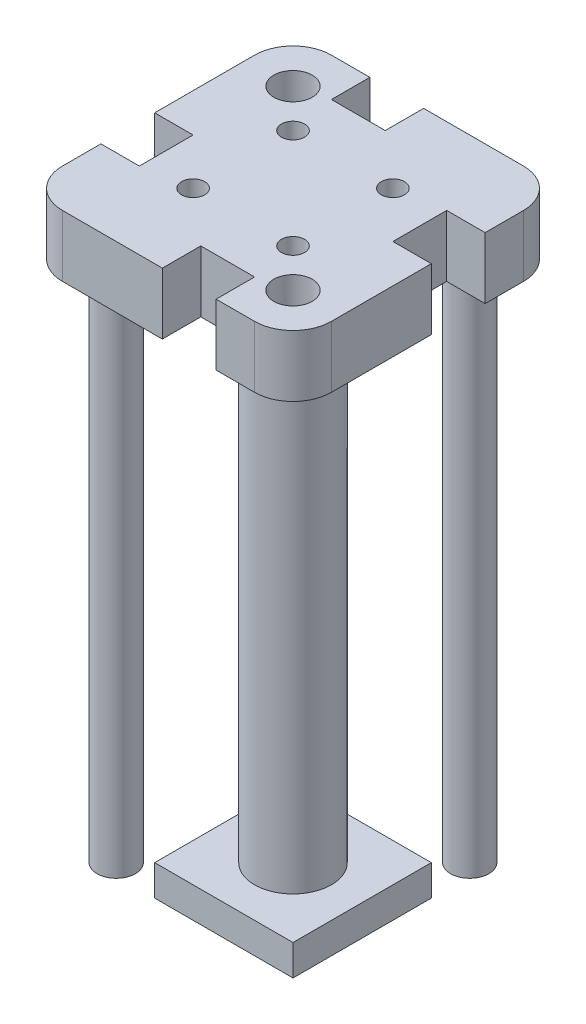
from build123d import *

# Parameters (mm, degrees)
SKETCH1_W           = 35
SKETCH1_H           = 35
BOSS_EXTRUDE1_DEPTH = 8
SKETCH2_W           = 7
SKETCH2_H           = 5
SKETCH2_W_2         = 5
SKETCH2_H_2         = 7
SKETCH2_R           = 1.5
CUT_EXTRUDE1_DEPTH  = 51.139804547
SKETCH2_5_R         = 4
SKETCH2_5_R_2       = 1.5
CUT_EXTRUDE2_DEPTH  = 4
SKETCH2_7_R         = 2.5
SKETCH2_7_R_2       = 5
BOSS_EXTRUDE2_DEPTH = 68
SKETCH3_W           = 18
SKETCH3_H           = 18
BOSS_EXTRUDE3_DEPTH = 4
FILLET1_R           = 5
SKETCH4_R           = 2.5
CUT_EXTRUDE3_DEPTH  = 10


with BuildPart() as part:
    # Sketch1 → Boss-Extrude1 (new body)
    with BuildSketch(Plane(origin=(0, 0, 0), x_dir=(1, 0, 0), z_dir=(0, 1, 0))):
        with Locations((17.5, 17.5)):
            Rectangle(SKETCH1_W, SKETCH1_H)
    extrude(amount=BOSS_EXTRUDE1_DEPTH)

    # Sketch2 → Cut-Extrude1 (cut, through all)
    with BuildSketch(Plane.XZ):
        with Locations((21.5, -2.5)):
            Rectangle(SKETCH2_W, SKETCH2_H)
        with Locations((2.5, -13.5)):
            Rectangle(SKETCH2_W_2, SKETCH2_H_2)
        with Locations((32.5, -21.5)):
            Rectangle(SKETCH2_W_2, SKETCH2_H_2)
        with Locations((13.5, -32.5)):
            Rectangle(SKETCH2_W, SKETCH2_H)
        with Locations((11, -11)):
            Circle(SKETCH2_R)
        with Locations((24, -11)):
            Circle(SKETCH2_R)
        with Locations((24, -24)):
            Circle(SKETCH2_R)
        with Locations((11, -24)):
            Circle(SKETCH2_R)
    extrude(amount=-CUT_EXTRUDE1_DEPTH, mode=Mode.SUBTRACT)

    # Sketch2_5 → Cut-Extrude2 (cut)
    with BuildSketch(Plane.XZ):
        with Locations((29, -6)):
            Circle(SKETCH2_5_R)
        with Locations((6, -29)):
            Circle(SKETCH2_5_R)
        with Locations((11, -11)):
            Circle(SKETCH2_5_R_2)
    extrude(amount=-CUT_EXTRUDE2_DEPTH, mode=Mode.SUBTRACT)

    # Sketch2_7 → Boss-Extrude2 (add)
    with BuildSketch(Plane.XZ):
        with Locations((6, -6)):
            Circle(SKETCH2_7_R)
        with Locations((29, -29)):
            Circle(SKETCH2_7_R)
        with Locations((17.5, -17.5)):
            Circle(SKETCH2_7_R_2)
    extrude(amount=BOSS_EXTRUDE2_DEPTH)

    # Sketch3 → Boss-Extrude3 (add)
    with BuildSketch(Plane(origin=(0, -68, 0), x_dir=(-1, 0, 0), z_dir=(0, -1, 0))):
        with Locations((-17.5, 17.5)):
            Rectangle(SKETCH3_W, SKETCH3_H)
    extrude(amount=BOSS_EXTRUDE3_DEPTH)

    # Fillet1
    fillet1_edges = [part.edges().sort_by_distance(p)[0] for p in [
        (35, 4, -35),
        (0, 4, -35),
        (0, 4, 0),
        (35, 4, 0),
    ]]
    fillet(fillet1_edges, radius=FILLET1_R)

    # Sketch4 → Cut-Extrude3 (cut)
    with BuildSketch(Plane(origin=(0, 4, 0), x_dir=(-1, 0, 0), z_dir=(0, -1, 0))):
        with Locations((-29, 6)):
            Circle(SKETCH4_R)
        with Locations((-6, 29)):
            Circle(SKETCH4_R)
    extrude(amount=-CUT_EXTRUDE3_DEPTH, mode=Mode.SUBTRACT)


solid = part.part
